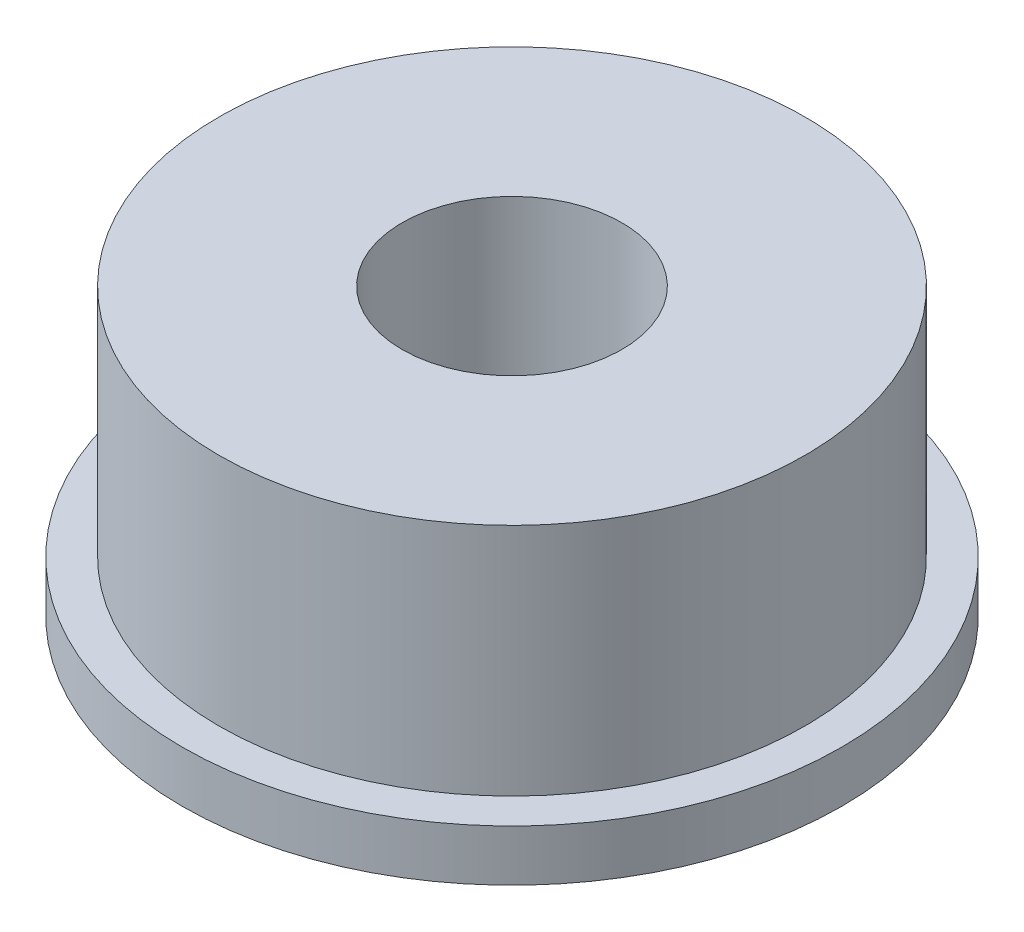
from build123d import *

# Parameters (mm, degrees)
SKETCH1_R           = 4.5
BOSS_EXTRUDE1_DEPTH = 0.7
SKETCH2_R           = 4
BOSS_EXTRUDE2_DEPTH = 3.2
SKETCH3_R           = 1.5
CUT_EXTRUDE1_DEPTH  = 4.9


with BuildPart() as part:
    # Sketch1 → Boss-Extrude1 (new body)
    with BuildSketch(Plane(origin=(0, 0, 0), x_dir=(1, 0, 0), z_dir=(0, 1, 0))):
        Circle(SKETCH1_R)
    extrude(amount=BOSS_EXTRUDE1_DEPTH)

    # Sketch2 → Boss-Extrude2 (add)
    with BuildSketch(Plane(origin=(0, 0.7, 0), x_dir=(1, 0, 0), z_dir=(0, 1, 0))):
        Circle(SKETCH2_R)
    extrude(amount=BOSS_EXTRUDE2_DEPTH)

    # Sketch3 → Cut-Extrude1 (cut, through all)
    with BuildSketch(Plane(origin=(0, 3.9, 0), x_dir=(1, 0, 0), z_dir=(0, 1, 0))):
        Circle(SKETCH3_R)
    extrude(amount=-CUT_EXTRUDE1_DEPTH, mode=Mode.SUBTRACT)


solid = part.part
